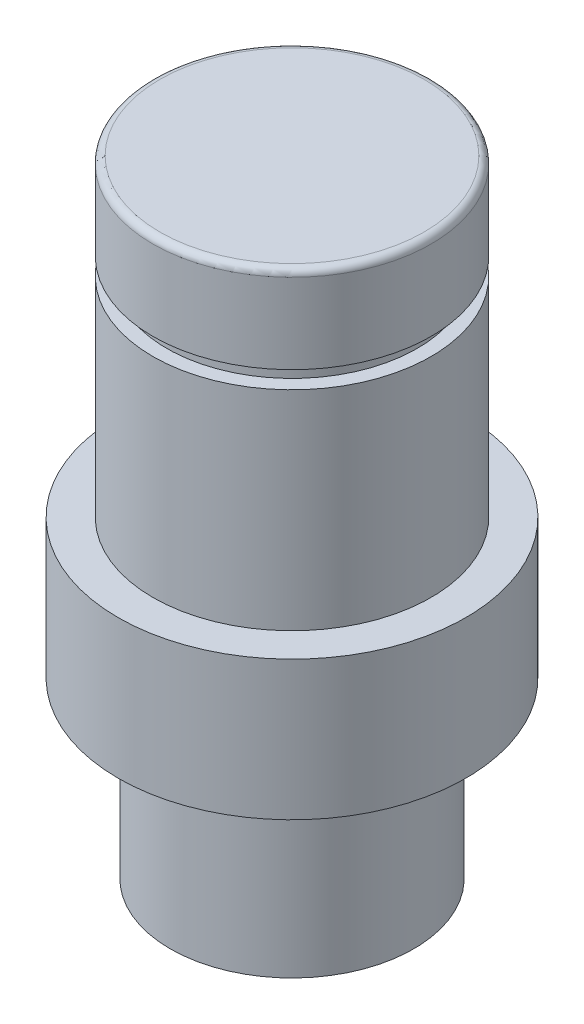
from build123d import *

# Parameters (mm, degrees)
FILLET1_R = 0.2


with BuildPart() as part:
    # Sketch2 → Revolve1 (revolve)
    with BuildSketch(Plane.XY):
        Polygon((-3.9451521, 11.195402299), (-3.9451521, 8.695402299), (-3.5451521, 8.695402299), (-3.5451521, 8.195402299), (-3.9451521, 8.195402299), (-3.9451521, 2.195402299), (-4.9451521, 2.195402299), (-4.9451521, -1.804597701), (-3.4451521, -1.804597701), (-3.4451521, -6.804597701), (0.0548479, -6.804597701), (0.0548479, 11.195402299), align=None)
    revolve(axis=Axis((0.0548479, -6.804597701, 0), (0, 1, 0)))

    # Fillet1
    fillet1_edges = [part.edges().sort_by_distance(p)[0] for p in [
        (4.0548479, 11.195402299, 0),
    ]]
    fillet(fillet1_edges, radius=FILLET1_R)


solid = part.part
